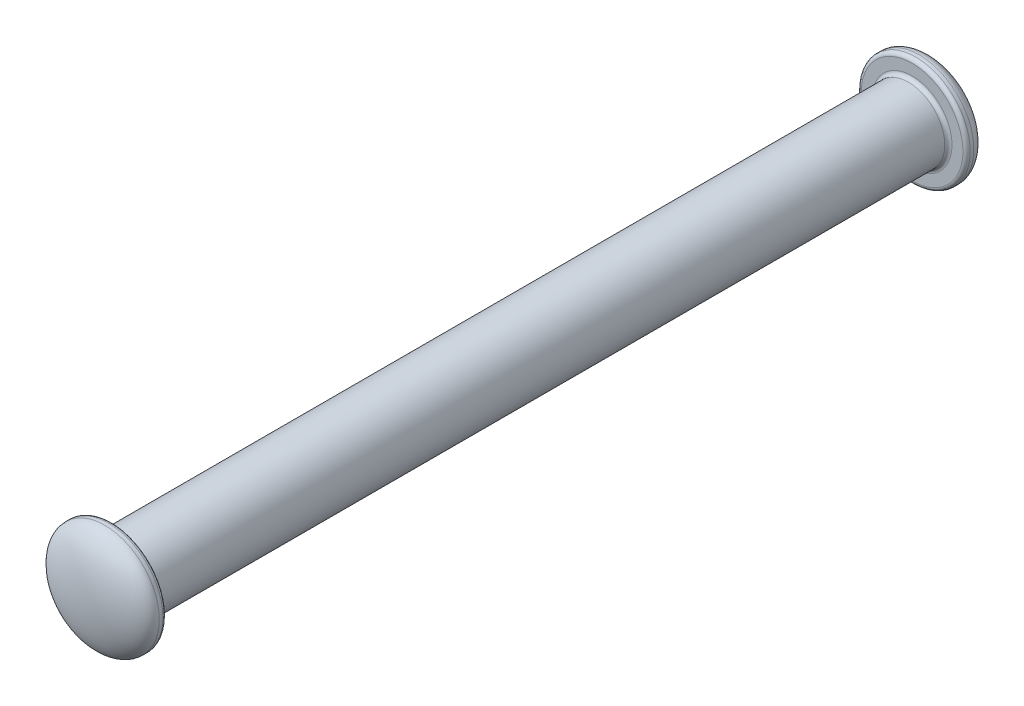
from build123d import *

# Parameters (mm, degrees)
SKETCH1_R           = 0.5
BOSS_EXTRUDE1_DEPTH = 11
SKETCH2_R           = 0.75
BOSS_EXTRUDE2_DEPTH = 0.1
BOSS_EXTRUDE3_START = 0.1
SKETCH3_R           = 0.75
BOSS_EXTRUDE3_DEPTH = 0.1
DOME1_FACE_RADIUS   = 0.75
DOME1_HEIGHT        = 0.3
DOME2_FACE_RADIUS   = 0.75
DOME2_HEIGHT        = 0.3
FILLET2_R           = 0.05


with BuildPart() as part:
    # Sketch1 → Boss-Extrude1 (new body)
    with BuildSketch(Plane.XY):
        Circle(SKETCH1_R)
    extrude(amount=BOSS_EXTRUDE1_DEPTH)

    # Sketch2 → Boss-Extrude2 (add)
    with BuildSketch(Plane.XY.offset(11)):
        Circle(SKETCH2_R)
    extrude(amount=BOSS_EXTRUDE2_DEPTH)

    # Sketch3 → Boss-Extrude3 (add)
    with BuildSketch(Plane(origin=(0, 0, 0), x_dir=(-1, 0, 0), z_dir=(0, 0, -1)).offset(BOSS_EXTRUDE3_START)):
        Circle(SKETCH3_R)
    extrude(amount=-BOSS_EXTRUDE3_DEPTH)

    # Dome1: an elliptical dome of height H over a round flat face of radius A is half a spheroid: the quarter ellipse of half axes A and H revolved about the face's axis
    with BuildSketch(Plane((0, 0, -0.1), x_dir=(0, -1, 0), z_dir=(1, 0, 0)), mode=Mode.PRIVATE) as dome1_quarter:
        Ellipse(DOME1_FACE_RADIUS, DOME1_HEIGHT)
        Rectangle(DOME1_FACE_RADIUS, DOME1_HEIGHT, align=(Align.MIN, Align.MIN), mode=Mode.INTERSECT)
    revolve(dome1_quarter.sketch, axis=Axis((0, 0, -0.1), (0, 0, -1)))

    # Dome2: an elliptical dome of height H over a round flat face of radius A is half a spheroid: the quarter ellipse of half axes A and H revolved about the face's axis
    with BuildSketch(Plane((0, 0, 11.1), x_dir=(0, 1, 0), z_dir=(1, 0, 0)), mode=Mode.PRIVATE) as dome2_quarter:
        Ellipse(DOME2_FACE_RADIUS, DOME2_HEIGHT)
        Rectangle(DOME2_FACE_RADIUS, DOME2_HEIGHT, align=(Align.MIN, Align.MIN), mode=Mode.INTERSECT)
    revolve(dome2_quarter.sketch, axis=Axis((0, 0, 11.1), (0, 0, 1)))

    # Fillet2
    fillet2_edges = [part.edges().sort_by_distance(p)[0] for p in [
        (-0.5, 0, 11),
        (-0.75, 0, 11),
        (-0.5, 0, 0),
        (0.75, 0, 0),
    ]]
    fillet(fillet2_edges, radius=FILLET2_R)


solid = part.part
